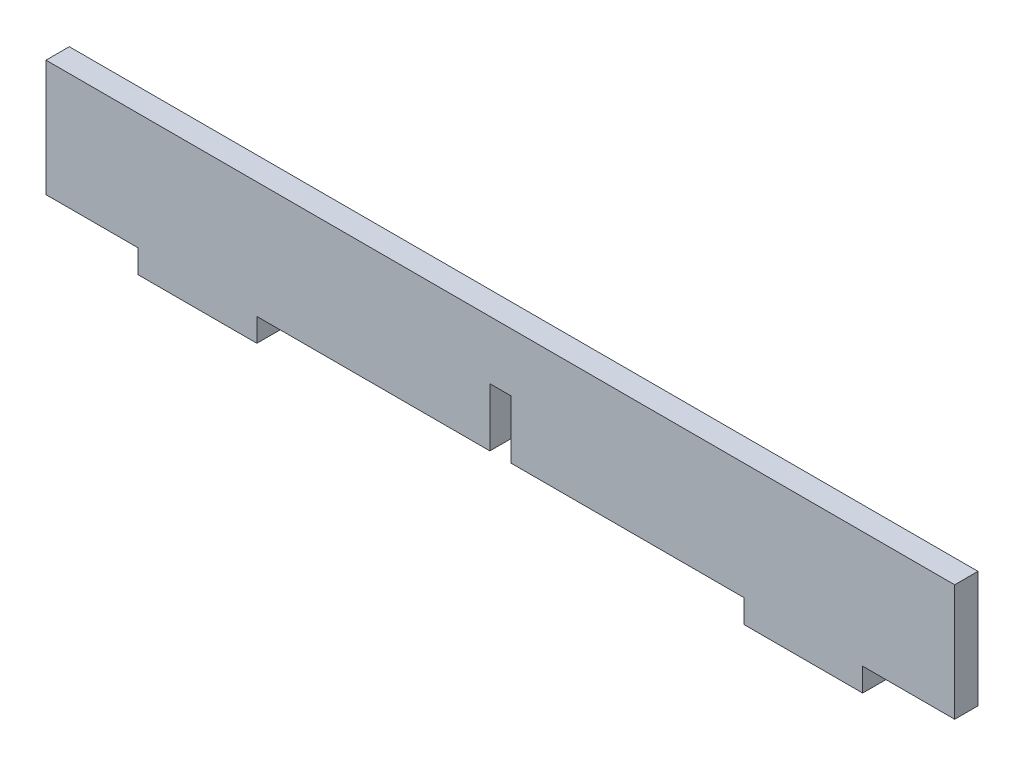
from build123d import *

# Parameters (mm, degrees)
EXTRUDE_1_DEPTH = 2


with BuildPart() as part:
    # 草圖1 → 填料-伸長1 (new body)
    with BuildSketch(Plane.XY):
        Polygon((-39, 2), (-31.1, 2), (-31.1, 0), (-20.9, 0), (-20.9, 2), (-0.9, 2), (-0.9, 7), (0.9, 7), (0.9, 2), (20.9, 2), (20.9, 0), (31.1, 0), (31.1, 2), (39, 2), (39, 12), (-39, 12), align=None)
    extrude(amount=EXTRUDE_1_DEPTH)


solid = part.part
